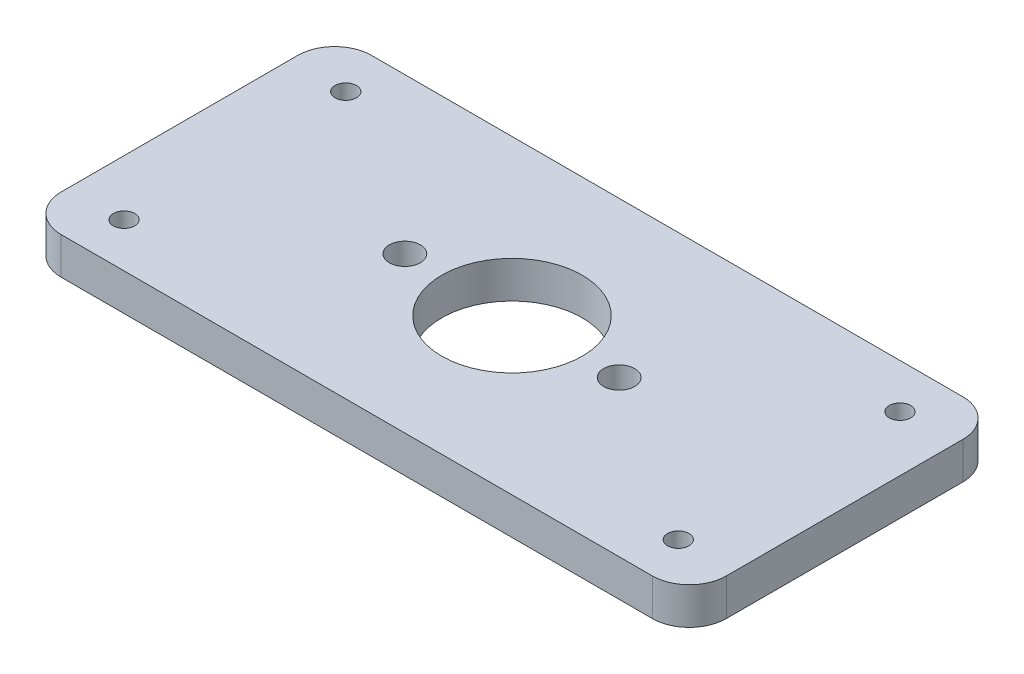
from build123d import *

# Parameters (mm, degrees)
SKETCH1_W           = 90
SKETCH1_H           = 42
SKETCH1_R           = 9.5
SKETCH1_R_2         = 2.1
SKETCH1_R_3         = 1.45
BOSS_EXTRUDE1_DEPTH = 5
FILLET1_R           = 5


with BuildPart() as part:
    # Sketch1 → Boss-Extrude1 (new body)
    with BuildSketch(Plane(origin=(0, 0, 0), x_dir=(1, 0, 0), z_dir=(0, 1, 0))):
        with Locations((45, 21)):
            Rectangle(SKETCH1_W, SKETCH1_H)
        with Locations((45, 21)):
            Circle(SKETCH1_R, mode=Mode.SUBTRACT)
        with Locations((59.5, 21)):
            Circle(SKETCH1_R_2, mode=Mode.SUBTRACT)
        with Locations((30.5, 21)):
            Circle(SKETCH1_R_2, mode=Mode.SUBTRACT)
        with Locations((7.5, 36)):
            Circle(SKETCH1_R_3, mode=Mode.SUBTRACT)
        with Locations((7.5, 6)):
            Circle(SKETCH1_R_3, mode=Mode.SUBTRACT)
        with Locations((82.5, 6)):
            Circle(SKETCH1_R_3, mode=Mode.SUBTRACT)
        with Locations((82.5, 36)):
            Circle(SKETCH1_R_3, mode=Mode.SUBTRACT)
    extrude(amount=BOSS_EXTRUDE1_DEPTH)

    # Fillet1
    fillet1_edges = [part.edges().sort_by_distance(p)[0] for p in [
        (0, 2.5, -42),
        (90, 2.5, -42),
        (90, 2.5, 0),
        (0, 2.5, 0),
    ]]
    fillet(fillet1_edges, radius=FILLET1_R)


solid = part.part
